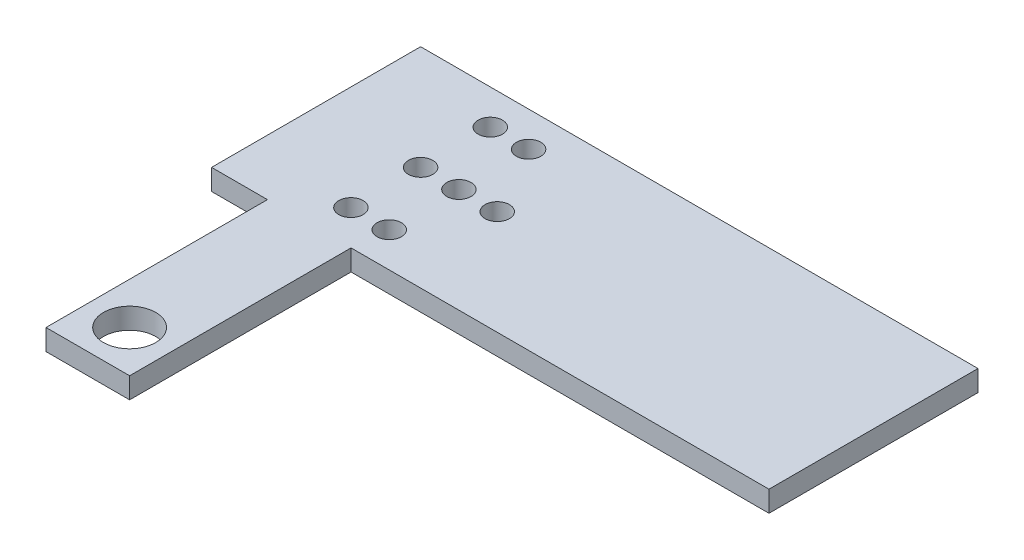
from build123d import *

# Parameters (mm, degrees)
SKETCH1_W           = 80
SKETCH1_H           = 30
BOSS_EXTRUDE1_DEPTH = 3
SKETCH2_R           = 1.75
CUT_EXTRUDE1_DEPTH  = 3
LPATTERN1_COUNT     = 3
LPATTERN1_PITCH     = 5.5
SKETCH3_R           = 1.75
CUT_EXTRUDE2_DEPTH  = 3
SKETCH4_W           = 12
SKETCH4_H           = 31.783850417
SKETCH4_R           = 3.75
BOSS_EXTRUDE2_DEPTH = 3


with BuildPart() as part:
    # Sketch1 → Boss-Extrude1 (new body)
    with BuildSketch(Plane(origin=(0, 0, 0), x_dir=(1, 0, 0), z_dir=(0, 1, 0))):
        Rectangle(SKETCH1_W, SKETCH1_H)
    extrude(amount=BOSS_EXTRUDE1_DEPTH)

    # Sketch2 → Cut-Extrude1 (cut)
    with BuildSketch(Plane(origin=(0, 3, 0), x_dir=(1, 0, 0), z_dir=(0, 1, 0))):
        with Locations((-25, 0)):
            Circle(SKETCH2_R)
    cut_extrude1 = extrude(amount=-CUT_EXTRUDE1_DEPTH, mode=Mode.SUBTRACT)

    # LPattern1: Cut-Extrude1 ×3
    with Locations(*[(i * LPATTERN1_PITCH, 0, 0) for i in range(1, LPATTERN1_COUNT)]):
        add(cut_extrude1, mode=Mode.SUBTRACT)

    # Sketch3 → Cut-Extrude2 (cut)
    with BuildSketch(Plane(origin=(0, 3, 0), x_dir=(1, 0, 0), z_dir=(0, 1, 0))):
        with Locations((-25, -10)):
            Circle(SKETCH3_R)
        with Locations((-19.5, -10)):
            Circle(SKETCH3_R)
    cut_extrude2 = extrude(amount=-CUT_EXTRUDE2_DEPTH, mode=Mode.SUBTRACT)

    # Mirror1: Cut-Extrude2 across plane
    add(cut_extrude2.mirror(Plane.XY), mode=Mode.SUBTRACT)

    # Sketch4 → Boss-Extrude2 (add)
    with BuildSketch(Plane(origin=(0, 0, 0), x_dir=(1, 0, 0), z_dir=(0, 1, 0))):
        with Locations((-25.982178222, -30.891925209)):
            Rectangle(SKETCH4_W, SKETCH4_H)
        with Locations((-25.982178222, -40.783850417)):
            Circle(SKETCH4_R, mode=Mode.SUBTRACT)
    extrude(amount=BOSS_EXTRUDE2_DEPTH)


solid = part.part
